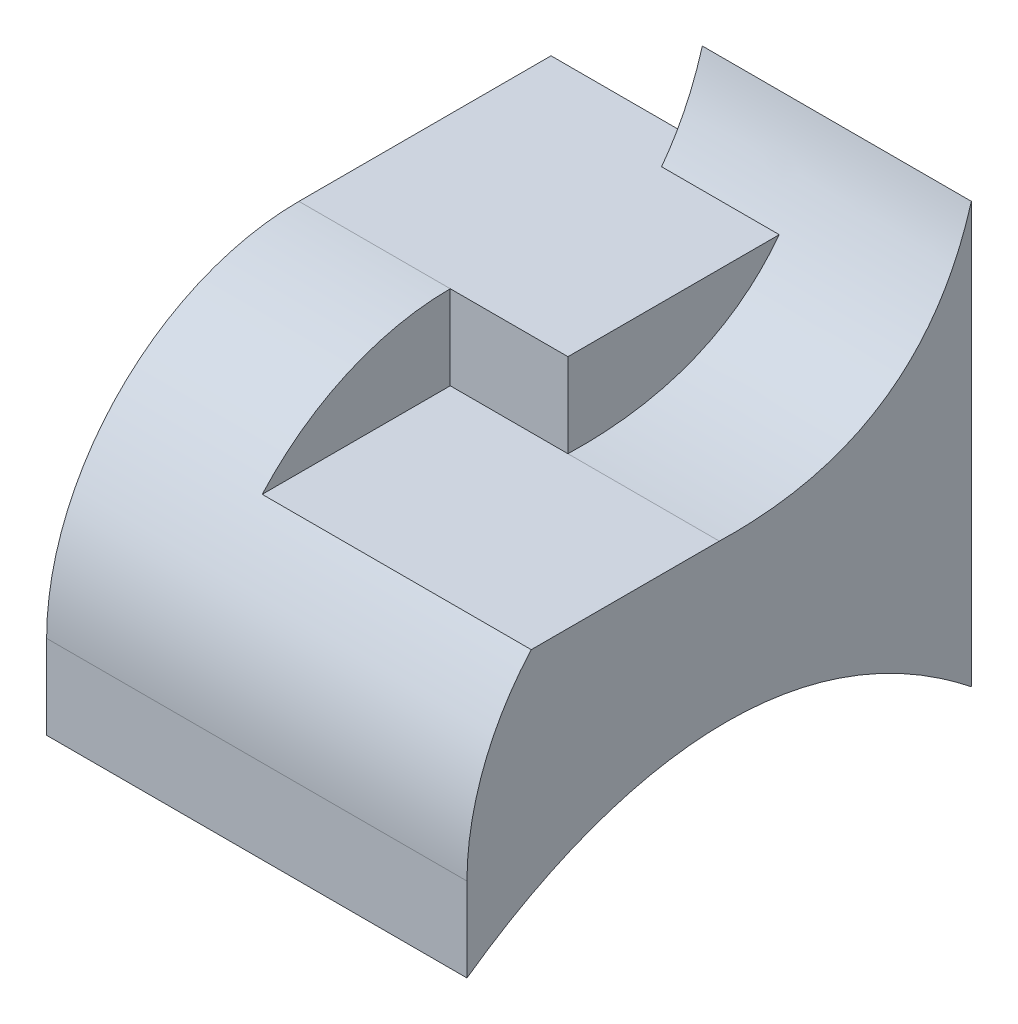
from build123d import *

# Parameters (mm, degrees)
BOSS_EXTRUDE1_DEPTH = 3.2
BOSS_EXTRUDE2_DEPTH = 1.8
BOSS_EXTRUDE3_DEPTH = 3.2


with BuildPart() as part:
    # Sketch1 → Boss-Extrude1 (new body)
    with BuildSketch(Plane(origin=(0, 0, 0), x_dir=(0, 0, -1), z_dir=(1, 0, 0))):
        with BuildLine():
            Line((2.000388773, 4), (-0.998443773, 4))
            Line((-0.998443773, 4), (-0.998443773, 1.094743417))
            add(Edge.make_bspline(
                [(2.000388773, 0), (0.565989501, 1.139941433), (-0.998443773, 1.094743417)],
                knots=[0, 0, 0, 0.519824709, 0.519824709, 0.519824709], degree=2))
            Line((2.000388773, 0), (2.000388773, 4))
        make_face()
    extrude(amount=BOSS_EXTRUDE1_DEPTH)

    # Sketch2 → Boss-Extrude2 (add)
    with BuildSketch(Plane.ZY):
        with BuildLine():
            add(Edge.make_bspline(
                [(0.998443773, 1.094743417), (2.014440988, 1.074460094), (3.030499337, 0.688991657), (3.999611226, 0)],
                knots=[0.49982829, 0.49982829, 0.49982829, 0.49982829, 1, 1, 1, 1], degree=3))
            Line((3.999611227, 0), (3.999611226, 0.998709843))
            ThreePointArc((3.999611226, 0.998709843), (3.120597073, 3.120899083), (0.998443773, 4))
            Line((0.998443773, 4), (0.998443773, 1.094743417))
        make_face()
    extrude(amount=-BOSS_EXTRUDE2_DEPTH)

    # Sketch3 → Boss-Extrude3 (add)
    with BuildSketch(Plane(origin=(1.8, 0, 0), x_dir=(0, 0, -1), z_dir=(1, 0, 0))):
        with BuildLine():
            add(Edge.make_bspline(
                [(-3.999611227, 0), (-3.02996408, 0.689665176), (-2.014175759, 1.074793835), (-0.998443773, 1.094743417)],
                knots=[0, 0, 0, 0, 0.50017171, 0.50017171, 0.50017171, 0.50017171], degree=3))
            Line((-0.998443773, 1.094743417), (-0.998443773, 3))
            Line((-0.998443773, 3), (-3.234965952, 3))
            ThreePointArc((-3.234965952, 3), (-3.801940417, 2.069905984), (-3.999611226, 0.998709843))
            Line((-3.999611227, 0.998709843), (-3.999611227, 0))
        make_face()
        with BuildLine():
            add(Edge.make_bspline(
                [(-0.998443773, 1.094743417), (0.016590806, 1.114679302), (1.031569126, 0.769937407), (2.000388773, 0)],
                knots=[0.50017171, 0.50017171, 0.50017171, 0.50017171, 1, 1, 1, 1], degree=3))
            Line((2.000388773, 0), (2.000388773, 5.000856569))
            add(Edge.make_bspline(
                [(2.000388773, 5.000856569), (1.39753578, 2.931475432), (-0.998443773, 3)],
                knots=[0, 0, 0, 1, 1, 1], degree=2))
            Line((-0.998443773, 3), (-0.998443773, 1.094743417))
        make_face()
    extrude(amount=BOSS_EXTRUDE3_DEPTH)


solid = part.part
